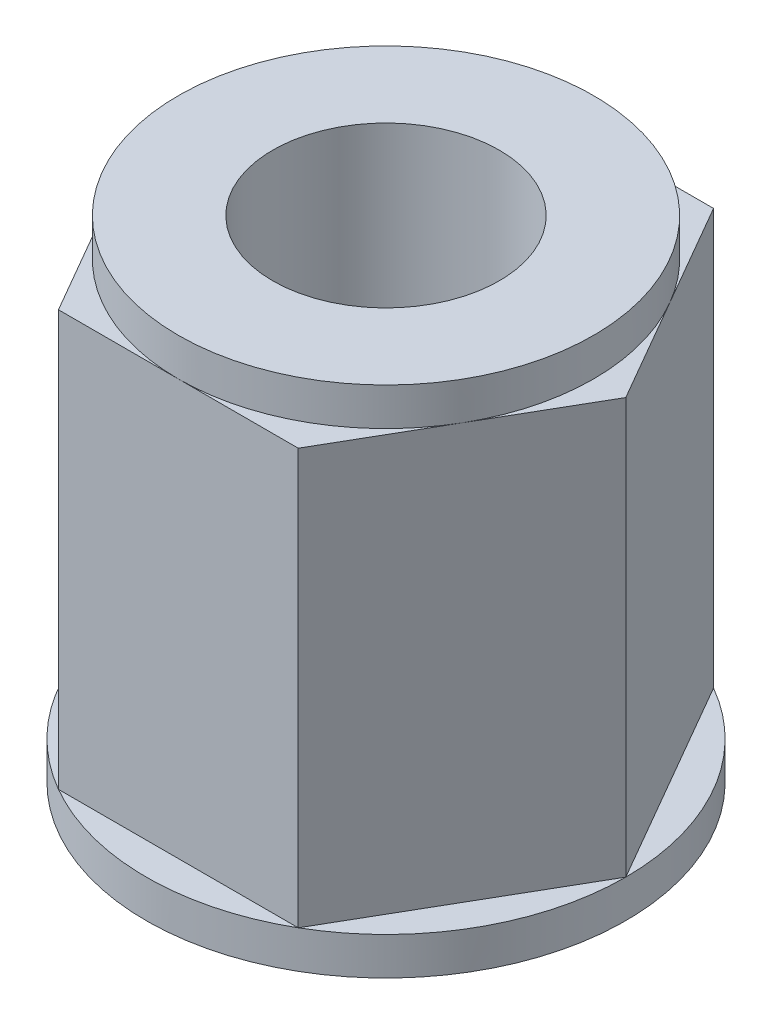
from build123d import *

# Parameters (mm, degrees)
ESTRUSIONE_ESTRUSIONE1_DEPTH = 11
SCHIZZO2_R                   = 6.35
ESTRUSIONE_ESTRUSIONE2_DEPTH = 1
SCHIZZO3_R                   = 5.499261314
ESTRUSIONE_ESTRUSIONE3_DEPTH = 1
FORO_0_6_0_6_1_D             = 6
FORO_0_6_0_6_1_DEPTH         = 13


with BuildPart() as part:
    # Schizzo1 → Estrusione-Estrusione1 (new body)
    with BuildSketch(Plane(origin=(0, 11, 0), x_dir=(1, 0, 0), z_dir=(0, 1, 0))):
        Polygon((-3.175, 5.499261314), (-6.35, 0), (-3.175, -5.499261314), (3.175, -5.499261314), (6.35, 0), (3.175, 5.499261314), align=None)
    extrude(amount=-ESTRUSIONE_ESTRUSIONE1_DEPTH)

    # Schizzo2 → Estrusione-Estrusione2 (add)
    with BuildSketch(Plane.XZ):
        Circle(SCHIZZO2_R)
    extrude(amount=ESTRUSIONE_ESTRUSIONE2_DEPTH)

    # Schizzo3 → Estrusione-Estrusione3 (add)
    with BuildSketch(Plane(origin=(0, 11, 0), x_dir=(-1, 0, 0), z_dir=(0, 1, 0))):
        Circle(SCHIZZO3_R)
    extrude(amount=ESTRUSIONE_ESTRUSIONE3_DEPTH)

    # Foro Ø0.6 (0.6)-1
    with Locations(Plane(origin=(0, -1, 0), x_dir=(-1, 0, 0), z_dir=(0, -1, 0))):
        with Locations((0, 0)):
            Hole(FORO_0_6_0_6_1_D / 2, depth=FORO_0_6_0_6_1_DEPTH)


solid = part.part
